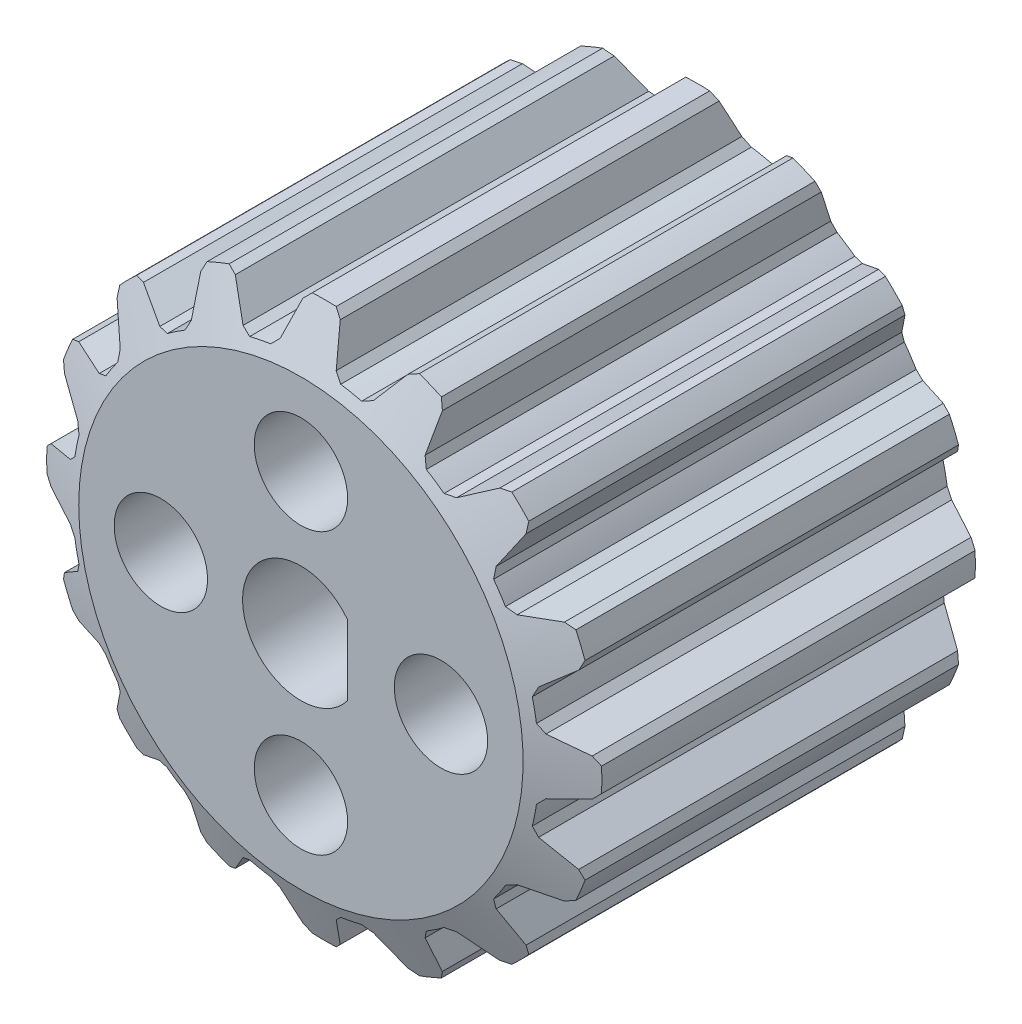
from build123d import *

# Parameters (mm, degrees)
SKETCH1_R           = 10
BOSS_EXTRUDE1_DEPTH = 18
CIRPATTERN1_COUNT   = 16
CUT_EXTRUDE1_DEPTH  = 37
SKETCH6_R           = 2
CUT_EXTRUDE2_DEPTH  = 37


with BuildPart() as part:
    # Sketch1 → Boss-Extrude1 (new body)
    with BuildSketch(Plane.XY):
        Circle(SKETCH1_R)
    extrude(amount=BOSS_EXTRUDE1_DEPTH)

    # Sweep1: sweep along a curve in space
    with BuildLine() as sweep1_path:
        Line((0, 11.890930062, 18), (0, 11.890930062, -2.071823773))
    # Sketch2 → Sweep1 (sweep)
    with BuildSketch(Plane.XY.offset(18)):
        with BuildLine():
            Line((-0.8, 11.589491158), (-1.2, 10.186859967))
            Line((-1.2, 10.186859967), (-1.5, 9.886859967))
            Line((-1.5, 9.886859967), (-1.5, 9.534464323))
            Line((-1.5, 9.534464323), (1.5, 9.534464323))
            Line((1.5, 9.534464323), (1.5, 9.886859967))
            Line((1.5, 9.886859967), (1.2, 10.186859967))
            Line((1.2, 10.186859967), (0.8, 11.589491158))
            Line((0.8, 11.589491158), (0.5, 11.889491158))
            ThreePointArc((0.5, 11.889491158), (0, 11.890930062), (-0.5, 11.889491158))
            Line((-0.5, 11.889491158), (-0.8, 11.589491158))
        make_face()
    sweep1 = sweep(path=sweep1_path.line)

    # CirPattern1: Sweep1 ×16 about axis
    cirpattern1_axis = Axis((0, 0, 0), (0, 0, 1))
    for i in range(1, CIRPATTERN1_COUNT):
        add(sweep1.rotate(cirpattern1_axis, i * 360 / CIRPATTERN1_COUNT))

    # Sketch4 → Cut-Extrude1 (cut)
    with BuildSketch(Plane.XY.offset(18)):
        with BuildLine():
            Line((2, 1.5), (2, -1.5))
            ThreePointArc((2, -1.5), (-2.5, 0), (2, 1.5))
        make_face()
    extrude(amount=-CUT_EXTRUDE1_DEPTH, mode=Mode.SUBTRACT)

    # Sketch5 → Cut-Revolve1 (revolve, cut)
    with BuildSketch(Plane(origin=(0, 0, 0), x_dir=(0, 0, -1), z_dir=(1, 0, 0))):
        Polygon((-17, 11.889491158), (-18, 9.517692956), (-22.180054692, 9.517692956), (-22.180054692, 15.258314789), (5.974041984, 15.258314789), (5.974041984, 9.517692956), (0, 9.517692956), (-1, 11.889491158), align=None)
    revolve(axis=Axis((0, 0, 0), (0, 0, 1)), mode=Mode.SUBTRACT)

    # Sketch6 → Cut-Extrude2 (cut)
    with BuildSketch(Plane.XY.offset(18)):
        with Locations((0, 6)):
            Circle(SKETCH6_R)
        with Locations((6, 0)):
            Circle(SKETCH6_R)
        with Locations((0, -6)):
            Circle(SKETCH6_R)
        with Locations((-6, 0)):
            Circle(SKETCH6_R)
    extrude(amount=-CUT_EXTRUDE2_DEPTH, mode=Mode.SUBTRACT)


solid = part.part
